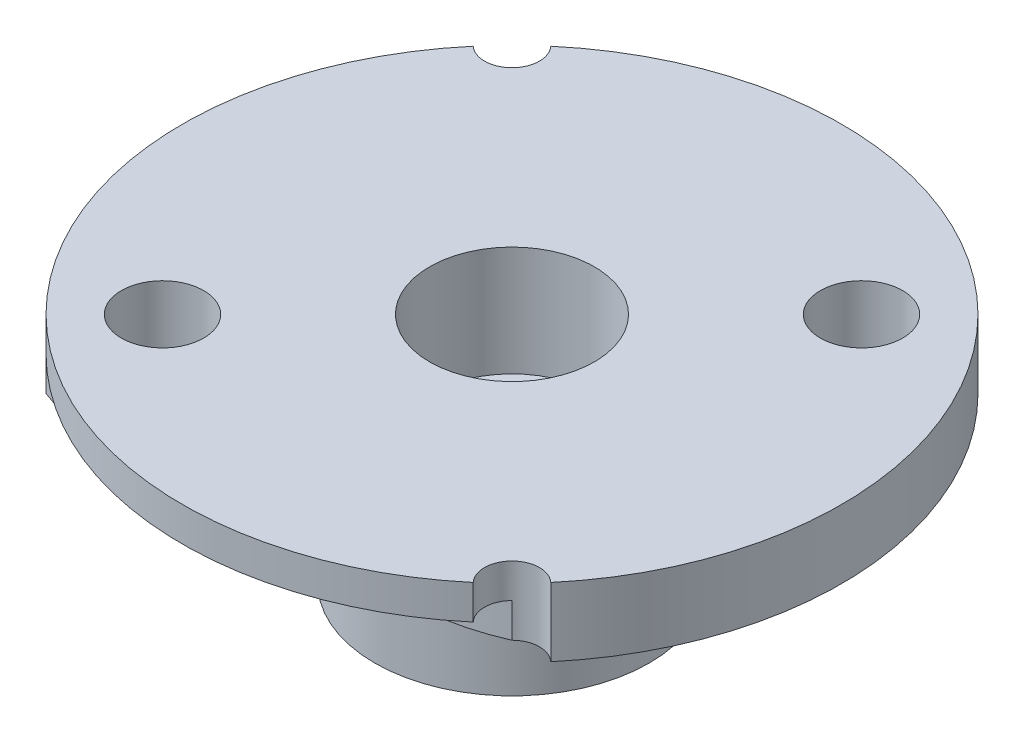
from build123d import *

# Parameters (mm, degrees)
CROQUIS1_R              = 12
SALIENTE_EXTRUIR1_DEPTH = 2.5
CROQUIS3_R              = 5
SALIENTE_EXTRUIR2_DEPTH = 6
CROQUIS2_R              = 3.001453564
CORTAR_EXTRUIR1_DEPTH   = 4
CROQUIS4_R              = 1.5
CORTAR_EXTRUIR2_DEPTH   = 8
CROQUIS5_R              = 2
CORTAR_EXTRUIR6_DEPTH   = 4
CROQUIS6_R              = 1.5
CORTAR_EXTRUIR7_DEPTH   = 4
CROQUIS7_R              = 1
CORTAR_EXTRUIR8_DEPTH   = 4
CORTAR_EXTRUIR9_DEPTH   = 1.25


with BuildPart() as part:
    # Croquis1 → Saliente-Extruir1 (new body)
    with BuildSketch(Plane(origin=(0, 0, 0), x_dir=(1, 0, 0), z_dir=(0, 1, 0))):
        Circle(CROQUIS1_R)
    extrude(amount=SALIENTE_EXTRUIR1_DEPTH)

    # Croquis3 → Saliente-Extruir2 (add)
    with BuildSketch(Plane.XZ):
        Circle(CROQUIS3_R)
    extrude(amount=SALIENTE_EXTRUIR2_DEPTH)

    # Croquis2 → Cortar-Extruir1 (cut)
    with BuildSketch(Plane(origin=(0, 2.5, 0), x_dir=(1, 0, 0), z_dir=(0, 1, 0))):
        Circle(CROQUIS2_R)
    extrude(amount=-CORTAR_EXTRUIR1_DEPTH, mode=Mode.SUBTRACT)

    # Croquis4 → Cortar-Extruir2 (cut)
    with BuildSketch(Plane(origin=(0, -1.5, 0), x_dir=(1, 0, 0), z_dir=(0, 1, 0))):
        Circle(CROQUIS4_R)
    extrude(amount=-CORTAR_EXTRUIR2_DEPTH, mode=Mode.SUBTRACT)

    # Croquis5 → Cortar-Extruir6 (cut)
    with BuildSketch(Plane.XZ.offset(6)):
        Circle(CROQUIS5_R)
    extrude(amount=-CORTAR_EXTRUIR6_DEPTH, mode=Mode.SUBTRACT)

    # Croquis6 → Cortar-Extruir7 (cut)
    with BuildSketch(Plane(origin=(0, 2.5, 0), x_dir=(1, 0, 0), z_dir=(0, 1, 0))):
        with Locations((6.363961031, 6.363961031)):
            Circle(CROQUIS6_R)
        with Locations((-6.363961031, -6.363961031)):
            Circle(CROQUIS6_R)
    extrude(amount=-CORTAR_EXTRUIR7_DEPTH, mode=Mode.SUBTRACT)

    # Croquis7 → Cortar-Extruir8 (cut)
    with BuildSketch(Plane.XZ):
        with Locations((8.485281374, 8.485281374)):
            Circle(CROQUIS7_R)
        with Locations((-8.485281374, -8.485281374)):
            Circle(CROQUIS7_R)
    extrude(amount=-CORTAR_EXTRUIR8_DEPTH, mode=Mode.SUBTRACT)

    # Croquis8 → Cortar-Extruir9 (cut)
    with BuildSketch(Plane.XZ):
        with BuildLine():
            ThreePointArc((7.778174593, 7.778174593), (7.485498506, 8.464443516), (7.749325885, 9.162311298))
            ThreePointArc((7.749325885, 9.162311298), (-0.5, 11.989578808), (-8.485281374, 8.485281374))
            add(Edge.make_bspline(
                [(-8.485281374, 8.485281374), (-7.592740334, 8.845120344), (-6.313852411, 9.008442263), (-4.858999126, 8.387047865), (-4.264313018, 7.608507158), (-4.072837383, 6.86756437), (-4.147476561, 6.387348921), (-3.967074672, 6.478559767)],
                knots=[0, 0, 0, 0, 0.492098519, 0.601947317, 0.788100157, 0.955757021, 1, 1, 1, 1], degree=3))
            add(Edge.make_bspline(
                [(7.778174593, 7.778174593), (6.043762471, 8.553284771), (1.93848679, 8.683425804), (-2.11467577, 7.905967318), (-3.967074672, 6.478559767)],
                knots=[0, 0, 0, 0, 0.452400817, 1, 1, 1, 1], degree=3))
        make_face()
        with BuildLine():
            ThreePointArc((-7.749325885, -9.162311298), (0.5, -11.989578808), (8.485281374, -8.485281374))
            add(Edge.make_bspline(
                [(8.485281374, -8.485281374), (7.761300195, -8.818220731), (6.448317824, -9.091275119), (4.851033429, -8.31231131), (4.115527792, -7.425847437), (3.966487119, -6.478710331), (3.548635711, -6.917914395)],
                knots=[0, 0, 0, 0, 0.407620337, 0.622914437, 0.853292729, 1, 1, 1, 1], degree=3))
            add(Edge.make_bspline(
                [(-7.778174593, -7.778174593), (-4.168772685, -9.273462944), (0.223344673, -9.411626111), (3.548635711, -6.917914395)],
                knots=[0, 0, 0, 0, 1, 1, 1, 1], degree=3))
            ThreePointArc((-7.778174593, -7.778174593), (-7.485498506, -8.464443516), (-7.749325885, -9.162311298))
        make_face()
    extrude(amount=-CORTAR_EXTRUIR9_DEPTH, mode=Mode.SUBTRACT)


solid = part.part
